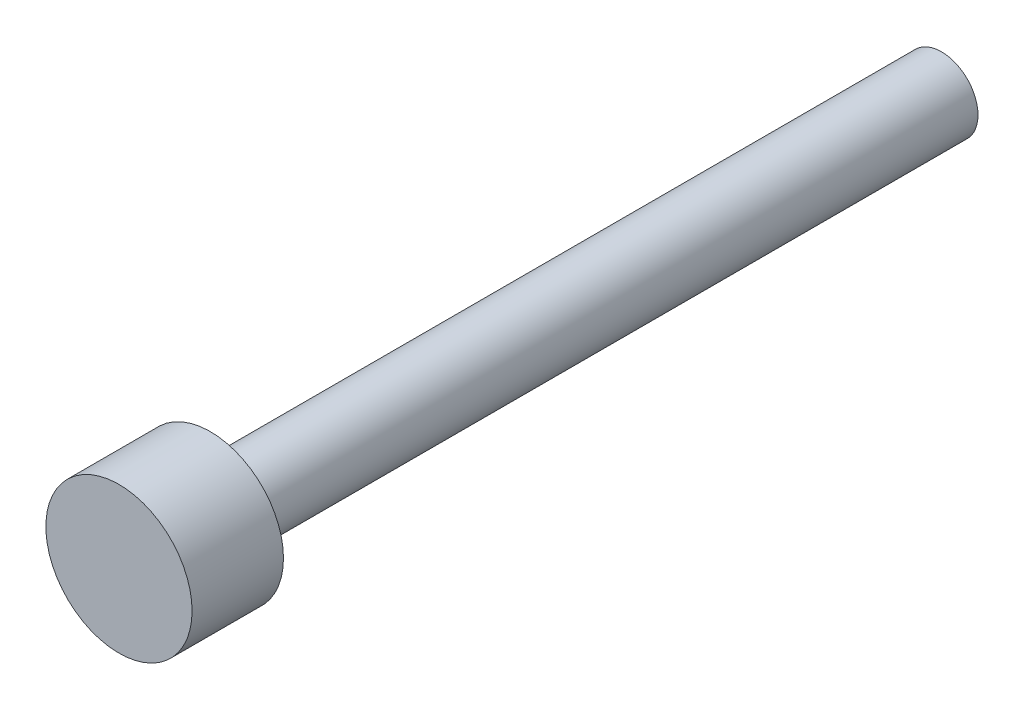
from build123d import *

# Parameters (mm, degrees)
ESQUISSE1_R        = 4
BOSS_EXTRU_1_DEPTH = 5
ESQUISSE2_R        = 2
BOSS_EXTRU_2_DEPTH = 40


with BuildPart() as part:
    # Esquisse1 → Boss.-Extru.1 (new body)
    with BuildSketch(Plane.XY):
        Circle(ESQUISSE1_R)
    extrude(amount=BOSS_EXTRU_1_DEPTH)

    # Esquisse2 → Boss.-Extru.2 (add)
    with BuildSketch(Plane.XY):
        Circle(ESQUISSE2_R)
    extrude(amount=-BOSS_EXTRU_2_DEPTH)


solid = part.part
